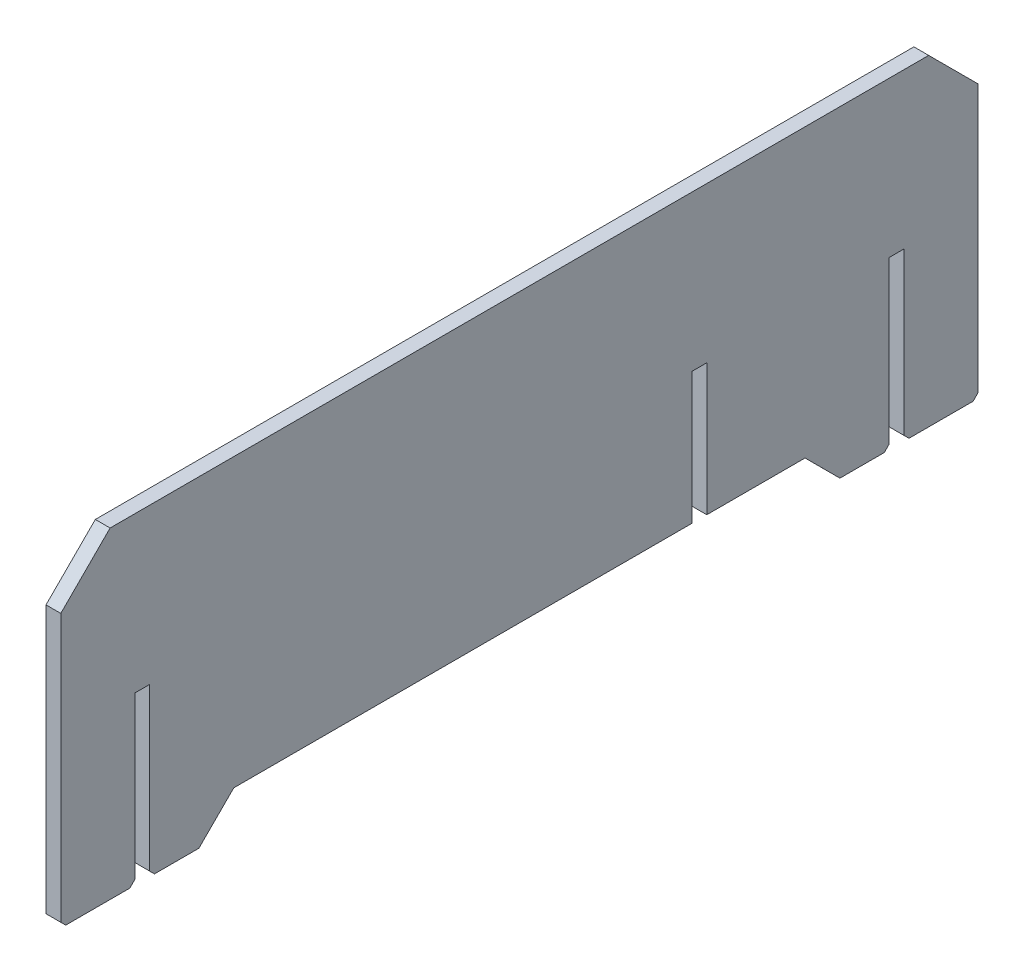
from build123d import *

# Parameters (mm, degrees)
SKETCH1_W                = 3
SKETCH1_H                = 7.073755714
SKETCH1_H_2              = 58.176244286
BOSS_EXTRUDE1_DEPTH      = 15
BOSS_EXTRUDE1_DEPTH_BACK = 171
CUT_EXTRUDE1_REACH       = 5
SKETCH2_W                = 3
SKETCH2_H                = 7.071067812
SKETCH2_H_2              = 26.692349798
CHAMFER1_SIZE            = 10
SKETCH5_W                = 3
SKETCH5_H                = 3
CUT_EXTRUDE2_DEPTH       = 1.002687902
CUT_EXTRUDE3_REACH       = 2.003
SKETCH6_W                = 3
SKETCH6_H                = 3
CHAMFER2_SIZE            = 1


with BuildPart() as part:
    # Sketch1 → Boss-Extrude1 (new body, two sides)
    with BuildSketch(Plane.XY) as boss_extrude1_sk:
        with Locations((-220.627859803, -123.051259948)):
            Rectangle(SKETCH1_W, SKETCH1_H)
        with Locations((-220.627859803, -90.426259948)):
            Rectangle(SKETCH1_W, SKETCH1_H_2)
    extrude(amount=BOSS_EXTRUDE1_DEPTH)
    extrude(boss_extrude1_sk.sketch, amount=-BOSS_EXTRUDE1_DEPTH_BACK)

    # Sketch2 → Cut-Extrude1 (cut, up to next)
    with BuildSketch(Plane(origin=(-219.127859803, 0, 0), x_dir=(0, 0, -1), z_dir=(1, 0, 0)), mode=Mode.PRIVATE) as cut_extrude1_sk1:
        with Locations((1.5, -123.049915997)):
            Rectangle(SKETCH2_W, SKETCH2_H)
    cut_extrude1_tool1 = extrude(cut_extrude1_sk1.sketch, amount=-CUT_EXTRUDE1_REACH, mode=Mode.PRIVATE) & part.part
    add(cut_extrude1_tool1.solids().sort_by_distance((-219.12786, -123.049916, -1.5))[0], mode=Mode.SUBTRACT)
    # Sketch2 → Cut-Extrude1 (cut, up to next)
    with BuildSketch(Plane(origin=(-219.127859803, 0, 0), x_dir=(0, 0, -1), z_dir=(1, 0, 0)), mode=Mode.PRIVATE) as cut_extrude1_sk2:
        with Locations((1.5, -106.168207192)):
            Rectangle(SKETCH2_W, SKETCH2_H_2)
    cut_extrude1_tool2 = extrude(cut_extrude1_sk2.sketch, amount=-CUT_EXTRUDE1_REACH, mode=Mode.PRIVATE) & part.part
    add(cut_extrude1_tool2.solids().sort_by_distance((-219.12786, -106.168207, -1.5))[0], mode=Mode.SUBTRACT)
    # Sketch2 → Cut-Extrude1 (cut, up to next)
    with BuildSketch(Plane(origin=(-219.127859803, 0, 0), x_dir=(0, 0, -1), z_dir=(1, 0, 0)), mode=Mode.PRIVATE) as cut_extrude1_sk3:
        Polygon((116, -126.585449903), (113, -126.585449903), (113, -119.514382091), (20.077559088, -119.514382091), (12.999999639, -126.588137805), (143, -126.588137805), (135.930045977, -119.514382091), (116, -119.514382091), align=None)
    cut_extrude1_tool3 = extrude(cut_extrude1_sk3.sketch, amount=-CUT_EXTRUDE1_REACH, mode=Mode.PRIVATE) & part.part
    add(cut_extrude1_tool3.solids().sort_by_distance((-219.12786, -123.120833, -77.089206))[0], mode=Mode.SUBTRACT)
    # Sketch2 → Cut-Extrude1 (cut, up to next)
    with BuildSketch(Plane(origin=(-219.127859803, 0, 0), x_dir=(0, 0, -1), z_dir=(1, 0, 0)), mode=Mode.PRIVATE) as cut_extrude1_sk4:
        with Locations((114.5, -123.049915997)):
            Rectangle(SKETCH2_W, SKETCH2_H)
    cut_extrude1_tool4 = extrude(cut_extrude1_sk4.sketch, amount=-CUT_EXTRUDE1_REACH, mode=Mode.PRIVATE) & part.part
    add(cut_extrude1_tool4.solids().sort_by_distance((-219.12786, -123.049916, -114.5))[0], mode=Mode.SUBTRACT)
    # Sketch2 → Cut-Extrude1 (cut, up to next)
    with BuildSketch(Plane(origin=(-219.127859803, 0, 0), x_dir=(0, 0, -1), z_dir=(1, 0, 0)), mode=Mode.PRIVATE) as cut_extrude1_sk5:
        with Locations((114.5, -106.168207192)):
            Rectangle(SKETCH2_W, SKETCH2_H_2)
    cut_extrude1_tool5 = extrude(cut_extrude1_sk5.sketch, amount=-CUT_EXTRUDE1_REACH, mode=Mode.PRIVATE) & part.part
    add(cut_extrude1_tool5.solids().sort_by_distance((-219.12786, -106.168207, -114.5))[0], mode=Mode.SUBTRACT)
    # Sketch2 → Cut-Extrude1 (cut, up to next)
    with BuildSketch(Plane(origin=(-219.127859803, 0, 0), x_dir=(0, 0, -1), z_dir=(1, 0, 0)), mode=Mode.PRIVATE) as cut_extrude1_sk6:
        with Locations((154.5, -123.049915997)):
            Rectangle(SKETCH2_W, SKETCH2_H)
    cut_extrude1_tool6 = extrude(cut_extrude1_sk6.sketch, amount=-CUT_EXTRUDE1_REACH, mode=Mode.PRIVATE) & part.part
    add(cut_extrude1_tool6.solids().sort_by_distance((-219.12786, -123.049916, -154.5))[0], mode=Mode.SUBTRACT)
    # Sketch2 → Cut-Extrude1 (cut, up to next)
    with BuildSketch(Plane(origin=(-219.127859803, 0, 0), x_dir=(0, 0, -1), z_dir=(1, 0, 0)), mode=Mode.PRIVATE) as cut_extrude1_sk7:
        with Locations((154.5, -106.168207192)):
            Rectangle(SKETCH2_W, SKETCH2_H_2)
    cut_extrude1_tool7 = extrude(cut_extrude1_sk7.sketch, amount=-CUT_EXTRUDE1_REACH, mode=Mode.PRIVATE) & part.part
    add(cut_extrude1_tool7.solids().sort_by_distance((-219.12786, -106.168207, -154.5))[0], mode=Mode.SUBTRACT)

    # Chamfer1
    chamfer1_edges = [part.edges().sort_by_distance(p)[0] for p in [
        (-220.627859803, -61.338137805, -171),
        (-220.627859803, -61.338137805, 15),
    ]]
    chamfer(chamfer1_edges, length=CHAMFER1_SIZE)

    # Sketch5 → Cut-Extrude2 (cut, through all)
    with BuildSketch(Plane(origin=(0, -126.585449903, 0), x_dir=(1, 0, 0), z_dir=(0, 1, 0))):
        with Locations((-220.627859803, 154.5)):
            Rectangle(SKETCH5_W, SKETCH5_H)
    extrude(amount=-CUT_EXTRUDE2_DEPTH, mode=Mode.SUBTRACT)

    # Sketch6 → Cut-Extrude3 (cut, up to next)
    with BuildSketch(Plane(origin=(0, -126.585449903, 0), x_dir=(1, 0, 0), z_dir=(0, 1, 0)), mode=Mode.PRIVATE) as cut_extrude3_sk1:
        with Locations((-220.627859803, 1.5)):
            Rectangle(SKETCH6_W, SKETCH6_H)
    cut_extrude3_tool1 = extrude(cut_extrude3_sk1.sketch, amount=-CUT_EXTRUDE3_REACH, mode=Mode.PRIVATE) & part.part
    add(cut_extrude3_tool1.solids().sort_by_distance((-220.62786, -126.58545, -1.5))[0], mode=Mode.SUBTRACT)

    # Chamfer2
    chamfer2_edges = [part.edges().sort_by_distance(p)[0] for p in [
        (-220.627859803, -126.588137805, -3),
        (-220.627859803, -126.588137805, 0),
        (-220.627859803, -126.588137805, 15),
        (-220.627859803, -126.588137805, -171),
        (-220.627859803, -126.588137805, -156),
        (-220.627859803, -126.588137805, -153),
    ]]
    chamfer(chamfer2_edges, length=CHAMFER2_SIZE)


solid = part.part
